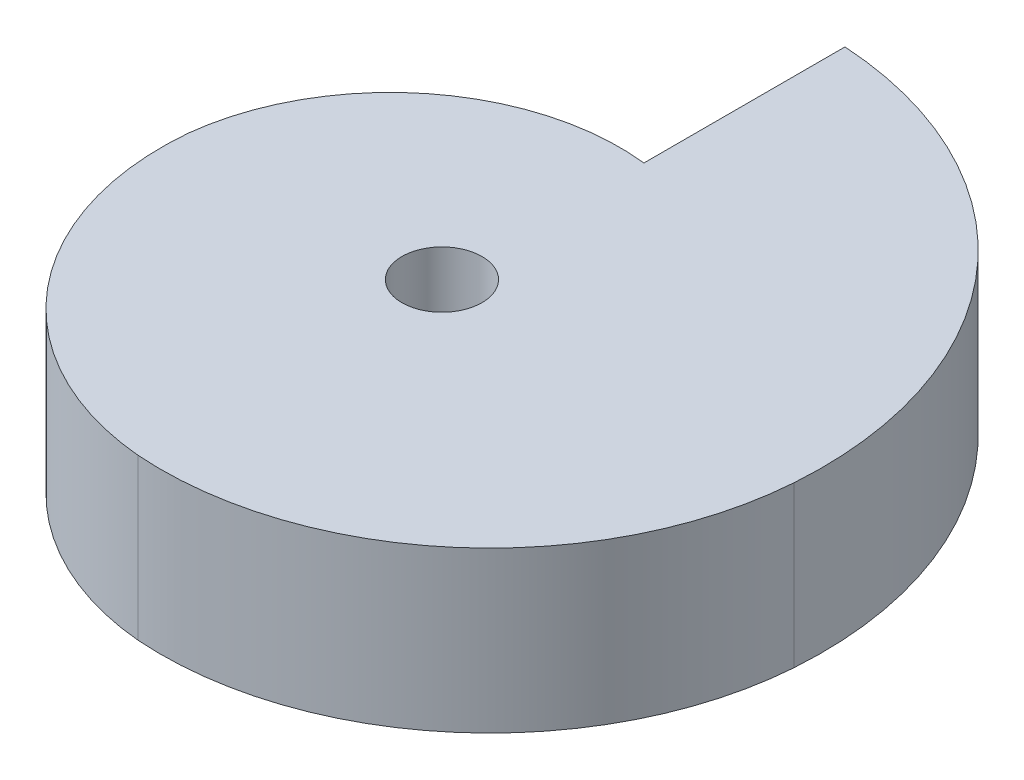
from build123d import *

# Parameters (mm, degrees)
SKETCH1_R           = 1.27
BOSS_EXTRUDE5_DEPTH = 5.08


with BuildPart() as part:
    # Sketch1 → Boss-Extrude5 (new body)
    with BuildSketch(Plane(origin=(0, 0, 0), x_dir=(1, 0, 0), z_dir=(0, 1, 0))):
        with BuildLine():
            Line((0, 6.405373718), (0, 12.781326863))
            ThreePointArc((0, 12.781326863), (8.247768787, 8.719637674), (11.161688458, 0))
            ThreePointArc((11.161688458, 0), (7.57811845, -7.133507881), (0, -9.643693024))
            ThreePointArc((0, -9.643693024), (-6.018946269, -6.487677618), (-8.043344095, 0))
            ThreePointArc((-8.043344095, 0), (-5.348268381, 4.868517964), (0, 6.405373718))
        make_face()
        Circle(SKETCH1_R, mode=Mode.SUBTRACT)
    extrude(amount=BOSS_EXTRUDE5_DEPTH)


solid = part.part
